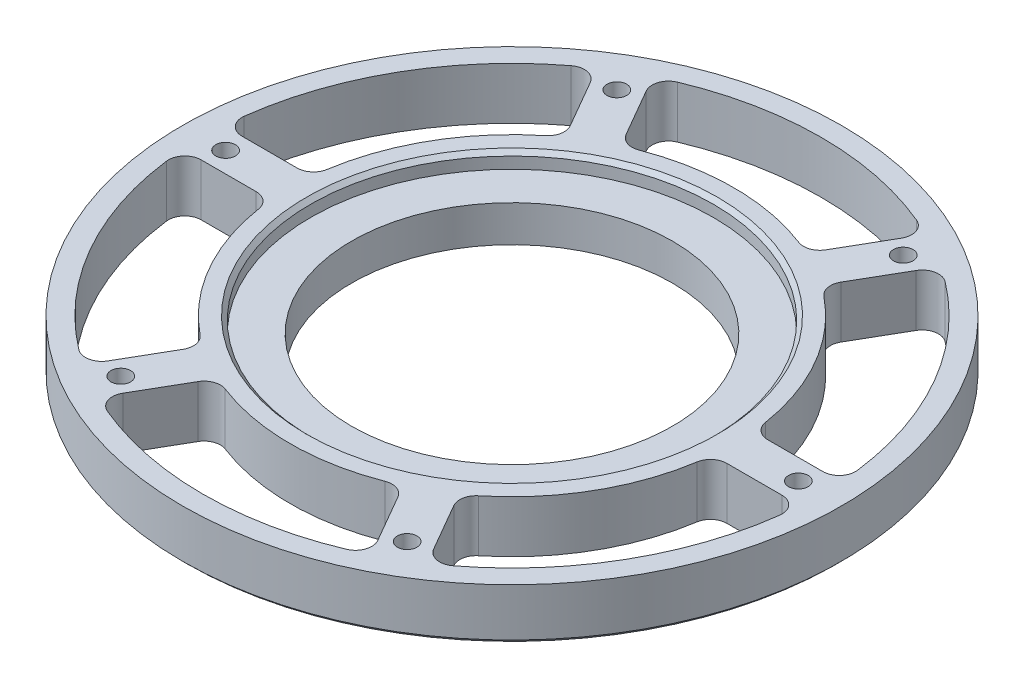
from build123d import *

# Parameters (mm, degrees)
F_12_0_189_DIAMETER_HOLE1_D = 4.8006
CIRPATTERN3_COUNT           = 6
CUT_EXTRUDE1_DEPTH          = 13.7
FILLET1_R                   = 4
CIRPATTERN4_COUNT           = 6
FILLET1_OF_CIRPATTERN4_R    = 4
CHAMFER1_SIZE               = 1
CHAMFER2_SIZE               = 1


with BuildPart() as part:
    # Sketch2 → Revolve1 (revolve)
    with BuildSketch(Plane(origin=(0, 0, 0), x_dir=(0, 0, -1), z_dir=(1, 0, 0))):
        Polygon((-39.2125, 0), (-80.55, 0), (-80.55, 12.7), (-49.2125, 12.7), (-49.2125, 8.9), (-39.2125, 8.9), align=None)
    revolve(axis=Axis((0, -0.635, 0), (0, 1, 0)))

    # #12 (0.189) Diameter Hole1 (through all)
    with Locations(Plane(origin=(0, 12.7, 0), x_dir=(1, 0, 0), z_dir=(0, 1, 0))):
        with Locations((-35, 60.621778)):
            f_12_0_189_diameter_hole1 = Hole(F_12_0_189_DIAMETER_HOLE1_D / 2)

    # CirPattern3: #12 (0.189) Diameter Hole1 ×6 about axis
    cirpattern3_axis = Axis((0, 0, 0), (0, 1, 0))
    for i in range(1, CIRPATTERN3_COUNT):
        add(f_12_0_189_diameter_hole1.rotate(cirpattern3_axis, i * 360 / CIRPATTERN3_COUNT), mode=Mode.SUBTRACT)

    # Sketch8 → Cut-Extrude1 (cut, through all)
    with BuildSketch(Plane(origin=(0, 12.7, 0), x_dir=(1, 0, 0), z_dir=(0, 1, 0))):
        with BuildLine():
            Line((-33.362056, 67.784775), (-22.66059, 49.249293))
            ThreePointArc((-22.66059, 49.249293), (0, 54.2125), (22.66059, 49.249293))
            Line((22.66059, 49.249293), (33.362056, 67.784775))
            ThreePointArc((33.362056, 67.784775), (0, 75.55), (-33.362056, 67.784775))
        make_face()
    cut_extrude1 = extrude(amount=-CUT_EXTRUDE1_DEPTH, mode=Mode.SUBTRACT)

    # Fillet1
    fillet1_edges = [part.edges().sort_by_distance(p)[0] for p in [
        (22.66059, 6.35, -49.249293),
        (-22.66059, 6.35, -49.249293),
        (-33.362056, 6.35, -67.784775),
        (33.362056, 6.35, -67.784775),
    ]]
    fillet(fillet1_edges, radius=FILLET1_R)

    # CirPattern4: Cut-Extrude1 ×6 about axis
    cirpattern4_axis = Axis((0, 0, 0), (0, 1, 0))
    for i in range(1, CIRPATTERN4_COUNT):
        add(cut_extrude1.rotate(cirpattern4_axis, i * 360 / CIRPATTERN4_COUNT), mode=Mode.SUBTRACT)

    # Fillet1 of CirPattern4
    fillet1_of_cirpattern4_edges = [part.edges().sort_by_distance(p)[0] for p in [
        (-31.320844, 6.35, -44.249293),
        (-53.981433, 6.35, -5),
        (-75.384365, 6.35, -5),
        (-42.02231, 6.35, -62.784775),
        (-53.981433, 6.35, 5),
        (-31.320844, 6.35, 44.249293),
        (-42.02231, 6.35, 62.784775),
        (-75.384365, 6.35, 5),
        (-22.66059, 6.35, 49.249293),
        (22.66059, 6.35, 49.249293),
        (33.362056, 6.35, 67.784775),
        (-33.362056, 6.35, 67.784775),
        (31.320844, 6.35, 44.249293),
        (53.981433, 6.35, 5),
        (75.384365, 6.35, 5),
        (42.02231, 6.35, 62.784775),
        (53.981433, 6.35, -5),
        (31.320844, 6.35, -44.249293),
        (42.02231, 6.35, -62.784775),
        (75.384365, 6.35, -5),
    ]]
    fillet(fillet1_of_cirpattern4_edges, radius=FILLET1_OF_CIRPATTERN4_R)

    # Chamfer1
    chamfer1_edges = [part.edges().sort_by_distance(p)[0] for p in [
        (0, 12.7, -49.2125),
    ]]
    chamfer(chamfer1_edges, length=CHAMFER1_SIZE)

    # Chamfer2
    chamfer2_edges = [part.edges().sort_by_distance(p)[0] for p in [
        (0, 0, -80.55),
    ]]
    chamfer(chamfer2_edges, length=CHAMFER2_SIZE)


solid = part.part
